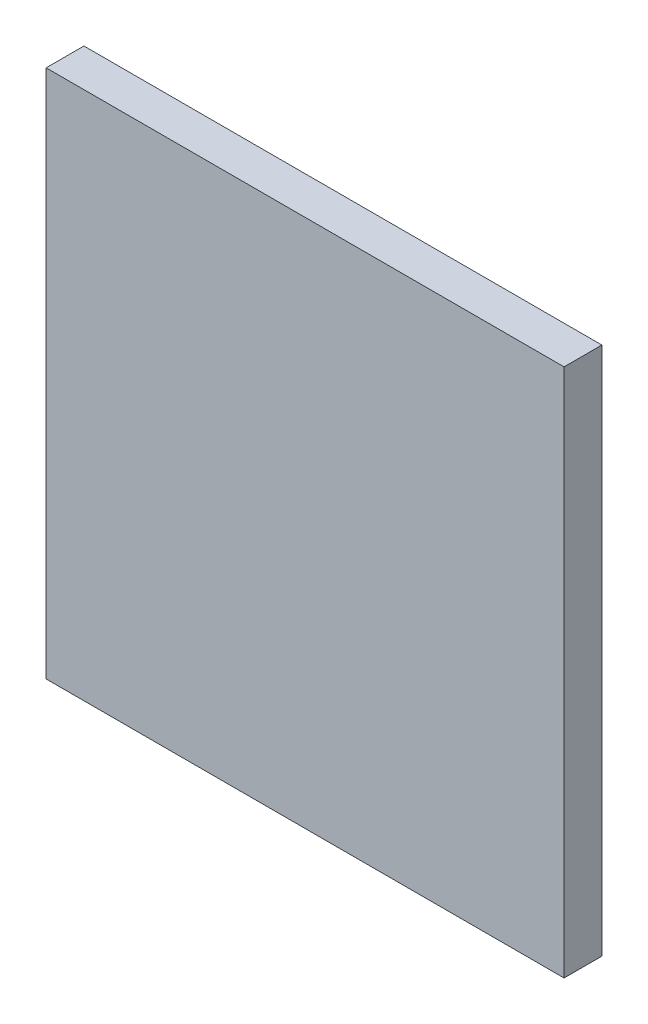
from build123d import *

# Parameters (mm, degrees)
SKETCH1_W           = 140
SKETCH1_H           = 137
BOSS_EXTRUDE1_DEPTH = 10


with BuildPart() as part:
    # Sketch1 → Boss-Extrude1 (new body)
    with BuildSketch(Plane(origin=(0, 0, 0), x_dir=(0, 1, 0), z_dir=(0, 0, 1))):
        Rectangle(SKETCH1_W, SKETCH1_H)
    extrude(amount=BOSS_EXTRUDE1_DEPTH)


solid = part.part
